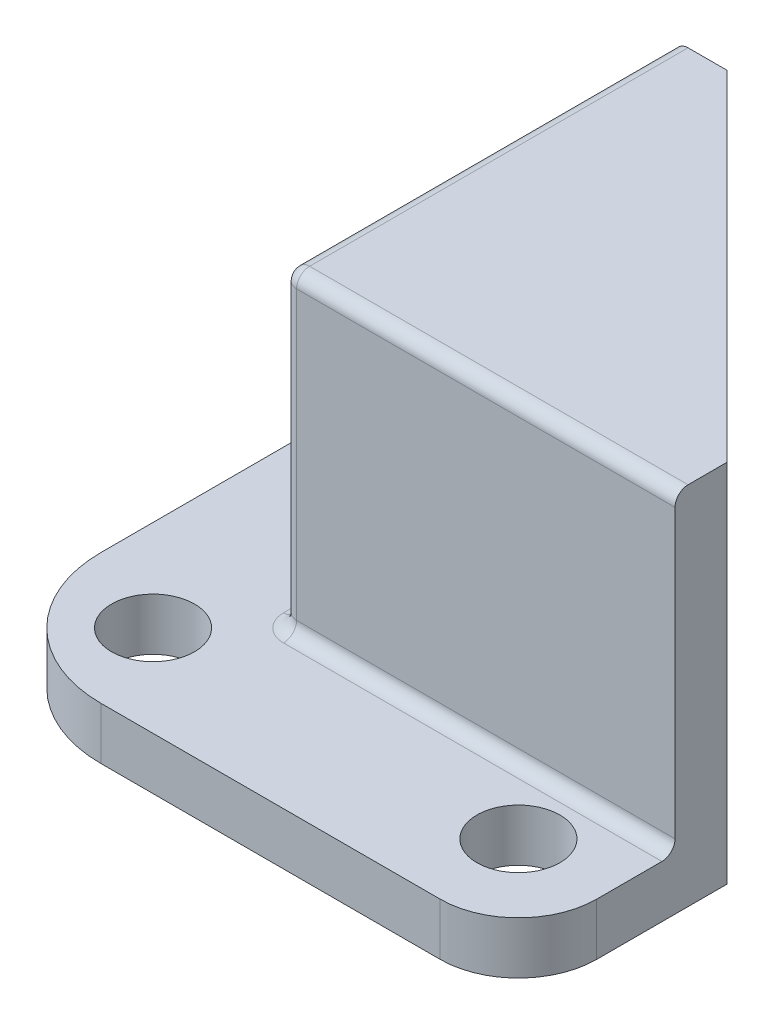
from build123d import *

# Parameters (mm, degrees)
BOSS_EXTRUDE1_DEPTH     = 12
BOSS_EXTRUDE2_DEPTH     = 2
BOSS_EXTRUDE3_DEPTH     = 2
CUT_EXTRUDE1_DEPTH      = 12
CUT_EXTRUDE1_DEPTH_BACK = 2
SKETCH3_R               = 1.5875
FILLET1_R               = 0.5


with BuildPart() as part:
    # Sketch1 → Boss-Extrude1 (new body)
    with BuildSketch(Plane(origin=(0, 0, 0), x_dir=(1, 0, 0), z_dir=(0, 1, 0))):
        Polygon((0, 15), (0, 0), (15, 0), (15, 2), (2, 2), (2, 15), align=None)
    extrude(amount=BOSS_EXTRUDE1_DEPTH)

    # Sketch1_3 → Boss-Extrude2 (add)
    with BuildSketch(Plane(origin=(0, 0, 0), x_dir=(1, 0, 0), z_dir=(0, 1, 0))):
        with BuildLine():
            Line((15, 0), (0, 0))
            Line((0, 0), (0, 15))
            Line((0, 15), (-3, 15))
            ThreePointArc((-3, 15), (-5.121320344, 14.121320344), (-6, 12))
            Line((-6, 12), (-6, -1))
            ThreePointArc((-6, -1), (-4.535533906, -4.535533906), (-1, -6))
            Line((-1, -6), (12, -6))
            ThreePointArc((12, -6), (14.121320344, -5.121320344), (15, -3))
            Line((15, -3), (15, 0))
        make_face()
    extrude(amount=BOSS_EXTRUDE2_DEPTH)

    # Sketch2 → Boss-Extrude3 (add)
    with BuildSketch(Plane(origin=(0, 12, 0), x_dir=(1, 0, 0), z_dir=(0, 1, 0))):
        Polygon((2, 15), (15, 2), (15, 0), (0, 0), (0, 15), align=None)
    extrude(amount=BOSS_EXTRUDE3_DEPTH)

    # Sketch3 → Cut-Extrude1 (cut, two sides: drawn at the far end of the back side and taken through both)
    with BuildSketch(Plane(origin=(0, 0, 0), x_dir=(1, 0, 0), z_dir=(0, 1, 0)).offset(-CUT_EXTRUDE1_DEPTH_BACK)):
        with Locations((-2.5, -2.5)):
            Circle(SKETCH3_R)
        with Locations((-2.5, 11.5)):
            Circle(SKETCH3_R)
        with Locations((11.5, -2.5)):
            Circle(SKETCH3_R)
    extrude(amount=CUT_EXTRUDE1_DEPTH + CUT_EXTRUDE1_DEPTH_BACK, mode=Mode.SUBTRACT)

    # Fillet1
    fillet1_edges = [part.edges().sort_by_distance(p)[0] for p in [
        (0, 2, -7.5),
        (7.5, 2, 0),
        (7.5, 14, 0),
        (0, 8, 0),
        (0, 14, -7.5),
    ]]
    fillet(fillet1_edges, radius=FILLET1_R)


solid = part.part
